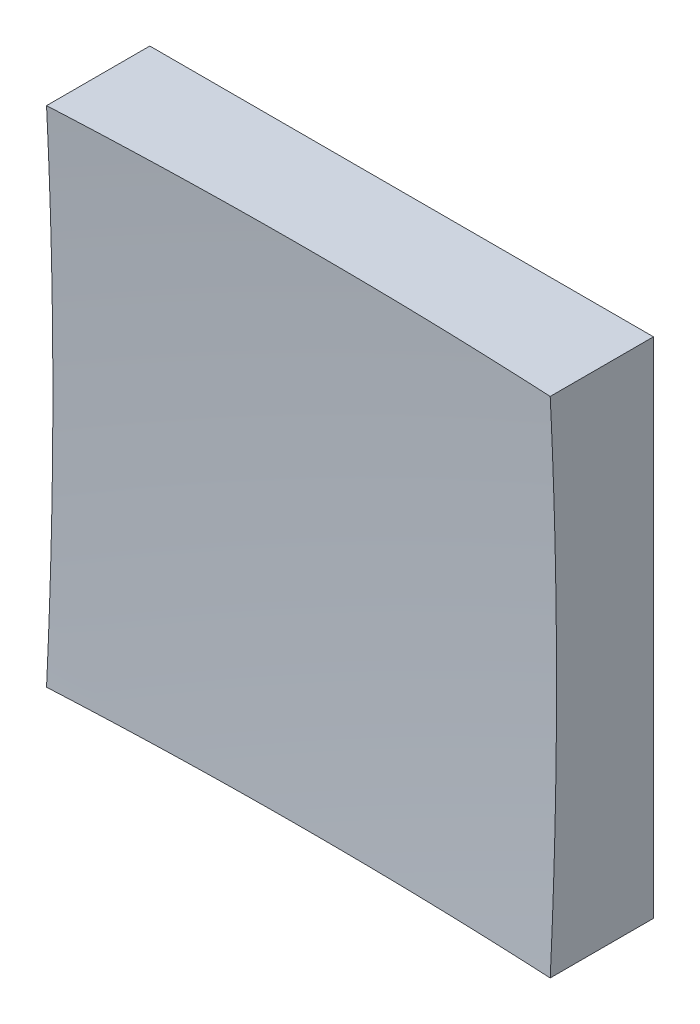
from build123d import *

# Parameters (mm, degrees)
SKETCH_1_W      = 50
SKETCH_1_H      = 50
EXTRUDE_1_DEPTH = 50


with BuildPart() as part:
    # 草图1 → 凸台-拉伸1 (new body)
    with BuildSketch(Plane.XY):
        Rectangle(SKETCH_1_W, SKETCH_1_H)
    extrude(amount=EXTRUDE_1_DEPTH)

    # 草图2 → 切除-旋转2 (revolve, cut)
    with BuildSketch(Plane(origin=(0, 0, 0), x_dir=(1, 0, 0), z_dir=(0, 1, 0))):
        with BuildLine():
            Line((487.422730906, -397.559067683), (0, -397.559067683))
            Line((0, -397.559067683), (0, -9))
            ThreePointArc((0, -9), (311.672531547, -118.026557067), (487.422730906, -397.559067683))
        make_face()
    revolve(axis=Axis((0, 0, 397.559067683), (0, 0, -1)), mode=Mode.SUBTRACT)


solid = part.part
